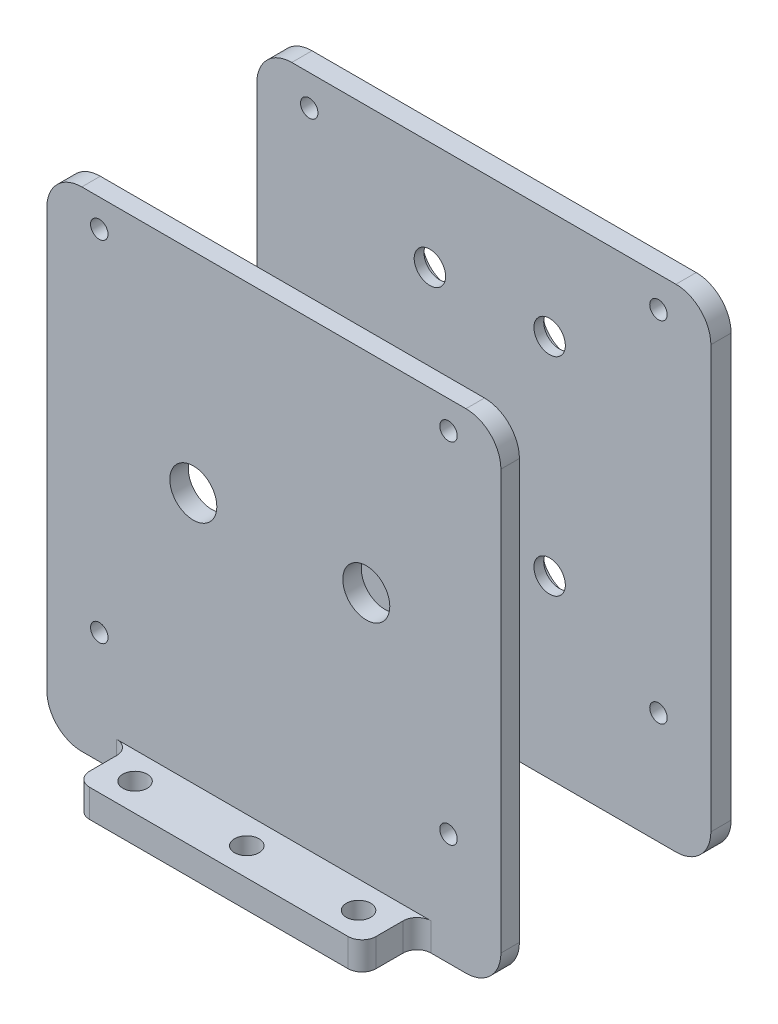
from build123d import *

# Parameters (mm, degrees)
SKETCH1_W                   = 65
SKETCH1_H                   = 70
BOSS_EXTRUDE1_DEPTH         = 2.65
FILLET1_R                   = 5
SKETCH2_W                   = 41
SKETCH2_H                   = 4
BOSS_EXTRUDE2_DEPTH         = 7.87989528
FILLET2_R                   = 2
SKETCH_1_R                  = 1.75
CUT_EXTRUDE_1_DEPTH         = 71
HOLE_WIZARD_M3_1_D          = 2.5
HOLE_WIZARD_M3_1_DEPTH      = 10
HOLE_WIZARD_M3_1_TIP        = 0.751075774
CUT_EXTRUDE_2_REACH         = 12.53
SKETCH_8_R                  = 3.3655
CUT_EXTRUDE_3_REACH         = 12.53
SKETCH_10_R                 = 3.3655
SKETCH_11_W                 = 65
SKETCH_11_H                 = 70.4
EXTRUDE_1_DEPTH             = 2.9
FILLET_2_R                  = 5
FILLET_3_R                  = 5
FILLET_4_R                  = 5
FILLET_5_R                  = 5
SKETCH_24_W                 = 1.25
SKETCH_24_H                 = 2.901
HOLE_WIZARD_M3_2_AT_2_COUNT = 2
HOLE_WIZARD_M3_2_AT_2_PITCH = 50
HOLE_WIZARD_M3_2_AT_3_COUNT = 2
HOLE_WIZARD_M3_2_AT_3_PITCH = 50
HOLE_WIZARD_M3_2_AT_4_COUNT = 2
HOLE_WIZARD_M3_2_AT_4_PITCH = 70.710678119
HOLE_WIZARD_M4_2_AT_2_COUNT = 2
HOLE_WIZARD_M4_2_AT_2_PITCH = 17.145
HOLE_WIZARD_M4_2_AT_3_COUNT = 2
HOLE_WIZARD_M4_2_AT_3_PITCH = 34.29
HOLE_WIZARD_M4_2_AT_4_COUNT = 2
HOLE_WIZARD_M4_2_AT_4_PITCH = 29.696011096


with BuildPart() as part:
    # Sketch1 → Boss-Extrude1 (new body)
    with BuildSketch(Plane.XY):
        Rectangle(SKETCH1_W, SKETCH1_H)
    extrude(amount=BOSS_EXTRUDE1_DEPTH)

    # Fillet1
    fillet1_edges = [part.edges().sort_by_distance(p)[0] for p in [
        (32.5, -35, 1.325),
        (-32.5, -35, 1.325),
        (-32.5, 35, 1.325),
        (32.5, 35, 1.325),
    ]]
    fillet(fillet1_edges, radius=FILLET1_R)

    # Sketch2 → Boss-Extrude2 (add)
    with BuildSketch(Plane.XY.offset(2.65)):
        with Locations((0, -33)):
            Rectangle(SKETCH2_W, SKETCH2_H)
    extrude(amount=BOSS_EXTRUDE2_DEPTH)

    # Fillet2
    fillet2_edges = [part.edges().sort_by_distance(p)[0] for p in [
        (-20.5, -33, 2.65),
        (20.5, -33, 2.65),
        (-20.5, -33, 10.52989528),
        (20.5, -33, 10.52989528),
    ]]
    fillet(fillet2_edges, radius=FILLET2_R)

    # 草图1 → 切除-拉伸1 (cut, through all)
    with BuildSketch(Plane.XZ.offset(35)):
        with Locations((-16, 6.52989528)):
            Circle(SKETCH_1_R)
        with Locations((0, 6.52989528)):
            Circle(SKETCH_1_R)
        with Locations((16, 6.52989528)):
            Circle(SKETCH_1_R)
    extrude(amount=-CUT_EXTRUDE_1_DEPTH, mode=Mode.SUBTRACT)

    # M3 螺纹孔1
    with Locations(Plane(origin=(25, -19, 0), x_dir=(-1, 0, 0), z_dir=(0, 0, -1))):
        with Locations((0, 0), (0, 50), (50, 50), (50, 0)):
            Hole(HOLE_WIZARD_M3_1_D / 2, depth=HOLE_WIZARD_M3_1_DEPTH)
            with Locations((0, 0, -(HOLE_WIZARD_M3_1_DEPTH + HOLE_WIZARD_M3_1_TIP / 2))):  # 118° drill point
                Cone(0, HOLE_WIZARD_M3_1_D / 2, HOLE_WIZARD_M3_1_TIP, mode=Mode.SUBTRACT)

    # 草图8 → 切除-拉伸2 (cut, up to next)
    with BuildSketch(Plane(origin=(0, 0, 0), x_dir=(-1, 0, 0), z_dir=(0, 0, -1)), mode=Mode.PRIVATE) as cut_extrude_2_sk1:
        with Locations((11.53725, 5.028)):
            Circle(SKETCH_8_R)
    cut_extrude_2_tool1 = extrude(cut_extrude_2_sk1.sketch, amount=-CUT_EXTRUDE_2_REACH, mode=Mode.PRIVATE) & part.part
    add(cut_extrude_2_tool1.solids().sort_by_distance((-11.53725, 5.028, 0))[0], mode=Mode.SUBTRACT)

    # 草图10 → 切除-拉伸3 (cut, up to next)
    with BuildSketch(Plane(origin=(0, 0, 0), x_dir=(-1, 0, 0), z_dir=(0, 0, -1)), mode=Mode.PRIVATE) as cut_extrude_3_sk1:
        with Locations((-13.22775, 5.028)):
            Circle(SKETCH_10_R)
    cut_extrude_3_tool1 = extrude(cut_extrude_3_sk1.sketch, amount=-CUT_EXTRUDE_3_REACH, mode=Mode.PRIVATE) & part.part
    add(cut_extrude_3_tool1.solids().sort_by_distance((13.22775, 5.028, 0))[0], mode=Mode.SUBTRACT)


with BuildPart() as body_2:
    # 草图11 → 凸台-拉伸1 (new body)
    with BuildSketch(Plane(origin=(0, 0, -30.31), x_dir=(-1, 0, 0), z_dir=(0, 0, -1))):
        with Locations((0, 0.2)):
            Rectangle(SKETCH_11_W, SKETCH_11_H)
    extrude(amount=-EXTRUDE_1_DEPTH)

    # 圆角2
    fillet_2_edges = [body_2.edges().sort_by_distance(p)[0] for p in [
        (-32.5, 35.4, -28.86),
    ]]
    fillet(fillet_2_edges, radius=FILLET_2_R)

    # 圆角3
    fillet_3_edges = [body_2.edges().sort_by_distance(p)[0] for p in [
        (-32.5, -35, -28.86),
    ]]
    fillet(fillet_3_edges, radius=FILLET_3_R)

    # 圆角4
    fillet_4_edges = [body_2.edges().sort_by_distance(p)[0] for p in [
        (32.5, -35, -28.86),
    ]]
    fillet(fillet_4_edges, radius=FILLET_4_R)

    # 圆角5
    fillet_5_edges = [body_2.edges().sort_by_distance(p)[0] for p in [
        (32.5, 35.4, -28.86),
    ]]
    fillet(fillet_5_edges, radius=FILLET_5_R)

    # 草图24 → M3 螺纹孔2 (revolve, cut)
    with BuildSketch(Plane(origin=(25, 31, -30.31), x_dir=(0, 1, 0), z_dir=(1, 0, 0))):
        with Locations((0.625, 1.4505)):
            Rectangle(SKETCH_24_W, SKETCH_24_H)
    hole_wizard_m3_2 = revolve(axis=Axis((25, 31, -36.66), (0, 0, 1)), mode=Mode.SUBTRACT)

    # M3 螺纹孔2 at 2: M3 螺纹孔2 ×2
    with Locations(*[(-i * HOLE_WIZARD_M3_2_AT_2_PITCH, 0, 0) for i in range(1, HOLE_WIZARD_M3_2_AT_2_COUNT)]):
        add(hole_wizard_m3_2, mode=Mode.SUBTRACT)

    # M3 螺纹孔2 at 3: M3 螺纹孔2 ×2
    with Locations(*[(0, -i * HOLE_WIZARD_M3_2_AT_3_PITCH, 0) for i in range(1, HOLE_WIZARD_M3_2_AT_3_COUNT)]):
        add(hole_wizard_m3_2, mode=Mode.SUBTRACT)

    # M3 螺纹孔2 at 4: M3 螺纹孔2 ×2
    with Locations(*[Vector(-0.707106781, -0.707106781, 0) * (i * HOLE_WIZARD_M3_2_AT_4_PITCH) for i in range(1, HOLE_WIZARD_M3_2_AT_4_COUNT)]):
        add(hole_wizard_m3_2, mode=Mode.SUBTRACT)

    # 草图27 → M4 六角凹头螺钉的柱形沉头孔2 (revolve, cut)
    with BuildSketch(Plane(origin=(9.41775, -9.820005548, -30.31), x_dir=(0, 1, 0), z_dir=(1, 0, 0))):
        Polygon((0, 0), (0, 32.96), (2.25, 32.96), (2.25, 1.5), (4, 1.5), (4, 0), align=None)
    hole_wizard_m4_2 = revolve(axis=Axis((9.41775, -9.820005548, -36.66), (0, 0, 1)), mode=Mode.SUBTRACT)

    # M4 六角凹头螺钉的柱形沉头孔2 at 2: M4 六角凹头螺钉的柱形沉头孔2 ×2
    with Locations(*[(-i * HOLE_WIZARD_M4_2_AT_2_PITCH, 0, 0) for i in range(1, HOLE_WIZARD_M4_2_AT_2_COUNT)]):
        add(hole_wizard_m4_2, mode=Mode.SUBTRACT)

    # M4 六角凹头螺钉的柱形沉头孔2 at 3: M4 六角凹头螺钉的柱形沉头孔2 ×2
    with Locations(*[Vector(-0.5, 0.866025404, 0) * (i * HOLE_WIZARD_M4_2_AT_3_PITCH) for i in range(1, HOLE_WIZARD_M4_2_AT_3_COUNT)]):
        add(hole_wizard_m4_2, mode=Mode.SUBTRACT)

    # M4 六角凹头螺钉的柱形沉头孔2 at 4: M4 六角凹头螺钉的柱形沉头孔2 ×2
    with Locations(*[(0, i * HOLE_WIZARD_M4_2_AT_4_PITCH, 0) for i in range(1, HOLE_WIZARD_M4_2_AT_4_COUNT)]):
        add(hole_wizard_m4_2, mode=Mode.SUBTRACT)


solid = Compound([part.part, body_2.part])
